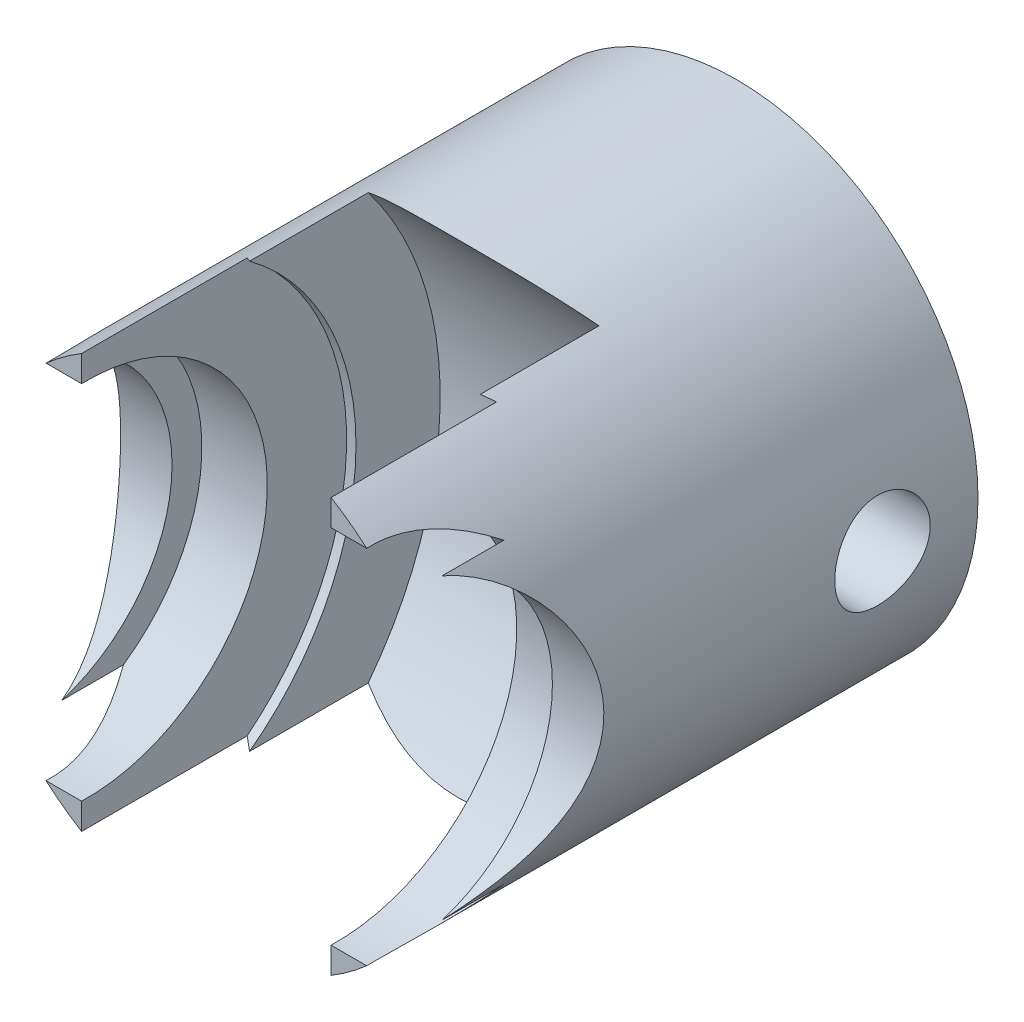
from build123d import *

# Parameters (mm, degrees)
SKETCH1_R           = 7.75
EXTRUDE1_DEPTH      = 17
EXTRUDE2_DEPTH      = 3.7
EXTRUDE2_DEPTH_BACK = 3.7
EXTRUDE3_DEPTH      = 4
EXTRUDE3_DEPTH_BACK = 4
SKETCH3_R           = 8.5
EXTRUDE4_DEPTH      = 21.226838767
EXTRUDE4_DEPTH_BACK = 21.226838767
SKETCH4_R           = 5
SKETCH4_R_2         = 1.53125
EXTRUDE5_DEPTH      = 6.1
EXTRUDE5_DEPTH_BACK = 6.1
SKETCH5_R           = 5.8


with BuildPart() as part:
    # Sketch1 → Extrude1 (new body)
    with BuildSketch(Plane.XY):
        Circle(SKETCH1_R)
    extrude(amount=EXTRUDE1_DEPTH)

    # Sketch2 → Extrude2 (cut, two sides: drawn at the far end of the back side and taken through both)
    with BuildSketch(Plane(origin=(0, 0, 0), x_dir=(0, 0, -1), z_dir=(1, 0, 0)).offset(-EXTRUDE2_DEPTH_BACK)):
        with BuildLine():
            Line((-17, 7.75), (-17, -7.81981982))
            Line((-17, -7.81981982), (-8.981869421, -7.81981982))
            ThreePointArc((-8.981869421, -7.81981982), (-5.800105265, -0.048558495), (-8.914364589, 7.75))
            Line((-8.914364589, 7.75), (-17, 7.75))
        make_face()
    extrude(amount=EXTRUDE2_DEPTH + EXTRUDE2_DEPTH_BACK, mode=Mode.SUBTRACT)

    # Sketch3 → Extrude3 (cut, two sides: drawn at the far end of the back side and taken through both)
    with BuildSketch(Plane(origin=(0, 0, 0), x_dir=(0, 0, -1), z_dir=(1, 0, 0)).offset(-EXTRUDE3_DEPTH_BACK)):
        with Locations((-17, 0)):
            Circle(SKETCH3_R)
    extrude(amount=EXTRUDE3_DEPTH + EXTRUDE3_DEPTH_BACK, mode=Mode.SUBTRACT)

    # Sketch4 → Extrude4 (cut, two sides: drawn at the far end of the back side and taken through both)
    with BuildSketch(Plane(origin=(0, 0, 0), x_dir=(0, 0, -1), z_dir=(1, 0, 0)).offset(-EXTRUDE4_DEPTH_BACK)):
        with Locations((-17, 0)):
            Circle(SKETCH4_R)
        with Locations((-3.0625, 0)):
            Circle(SKETCH4_R_2)
    extrude(amount=EXTRUDE4_DEPTH + EXTRUDE4_DEPTH_BACK, mode=Mode.SUBTRACT)

    # Sketch5 → Extrude5 (cut, two sides: drawn at the far end of the back side and taken through both)
    with BuildSketch(Plane(origin=(0, 0, 0), x_dir=(0, 0, -1), z_dir=(1, 0, 0)).offset(-EXTRUDE5_DEPTH_BACK)):
        with Locations((-16.84375, 0)):
            Circle(SKETCH5_R)
    extrude(amount=EXTRUDE5_DEPTH + EXTRUDE5_DEPTH_BACK, mode=Mode.SUBTRACT)


solid = part.part
